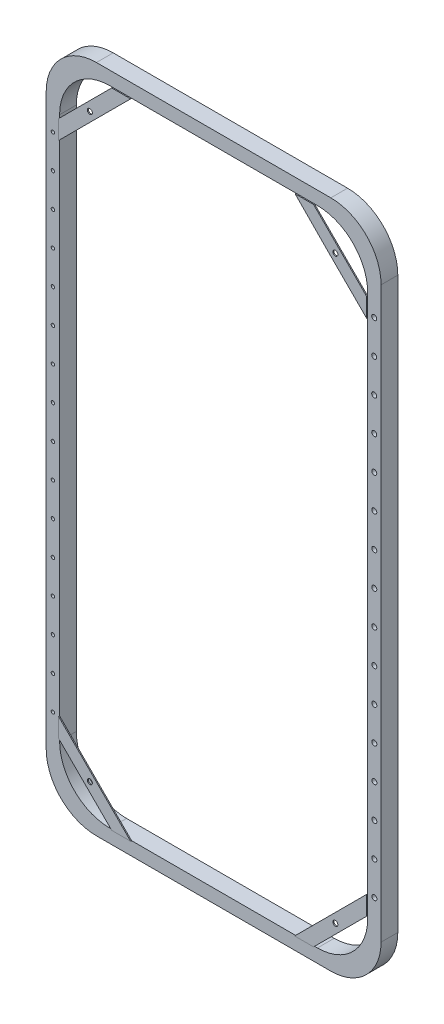
from build123d import *

# Parameters (mm, degrees)
ESTRUSIONE_ESTRUSIONE2_DEPTH = 50
RACCORDO2_R                  = 150
TAGLIO_ESTRUSIONE2_DEPTH     = 50
ESTRUSIONE_ESTRUSIONE5_DEPTH = 3
ESTRUSIONE_ESTRUSIONE6_DEPTH = 3
ESTRUSIONE_ESTRUSIONE7_DEPTH = 3
ESTRUSIONE_ESTRUSIONE8_DEPTH = 3
SCHIZZO11_R                  = 7.5
TAGLIO_ESTRUSIONE3_DEPTH     = 54
SCHIZZO12_R                  = 7.5
TAGLIO_ESTRUSIONE4_DEPTH     = 54
SCHIZZO13_R                  = 7.5
TAGLIO_ESTRUSIONE5_DEPTH     = 54
SCHIZZO14_R                  = 7.5
TAGLIO_ESTRUSIONE6_DEPTH     = 54
SCHIZZO15_R                  = 7.5
TAGLIO_ESTRUSIONE7_DEPTH     = 51
SCHIZZO16_R                  = 5
TAGLIO_ESTRUSIONE9_DEPTH     = 51


with BuildPart() as part:
    # Schizzo1 → Estrusione-Estrusione2 (new body)
    with BuildSketch(Plane.XY):
        Polygon((-204.549340991, 1000), (-500, 1000), (-500, -1000), (500, -1000), (500, 1000), align=None)
    extrude(amount=ESTRUSIONE_ESTRUSIONE2_DEPTH)

    # Raccordo2
    raccordo2_edges = [part.edges().sort_by_distance(p)[0] for p in [
        (500, -1000, 25),
        (-500, -1000, 25),
        (-500, 1000, 25),
        (500, 1000, 25),
    ]]
    fillet(raccordo2_edges, radius=RACCORDO2_R)

    # Schizzo4 → Taglio-Estrusione2 (cut)
    with BuildSketch(Plane.XY.offset(50)):
        with BuildLine():
            Line((-310, 960), (310, 960))
            ThreePointArc((310, 960), (416.066017178, 916.066017178), (460, 810))
            Line((460, 810), (460, -810))
            ThreePointArc((460, -810), (416.066017178, -916.066017178), (310, -960))
            Line((310, -960), (-310, -960))
            ThreePointArc((-310, -960), (-416.066017178, -916.066017178), (-460, -810))
            Line((-460, -810), (-460, 810))
            ThreePointArc((-460, 810), (-416.066017178, 916.066017178), (-310, 960))
        make_face()
    extrude(amount=-TAGLIO_ESTRUSIONE2_DEPTH, mode=Mode.SUBTRACT)

    # Schizzo15 → Taglio-Estrusione7 (cut, through all)
    with BuildSketch(Plane.XY.offset(50)):
        with Locations((480, -744.852813742)):
            Circle(SCHIZZO15_R)
        with Locations((479.972038493, -644.852817652)):
            Circle(SCHIZZO15_R)
        with Locations((479.944076987, -544.852821561)):
            Circle(SCHIZZO15_R)
        with Locations((479.91611548, -444.85282547)):
            Circle(SCHIZZO15_R)
        with Locations((479.888153974, -344.852829379)):
            Circle(SCHIZZO15_R)
        with Locations((479.860192467, -244.852833289)):
            Circle(SCHIZZO15_R)
        with Locations((479.83223096, -144.852837198)):
            Circle(SCHIZZO15_R)
        with Locations((479.804269454, -44.852841107)):
            Circle(SCHIZZO15_R)
        with Locations((479.776307947, 55.147154984)):
            Circle(SCHIZZO15_R)
        with Locations((479.748346441, 155.147151075)):
            Circle(SCHIZZO15_R)
        with Locations((479.720384934, 255.147147165)):
            Circle(SCHIZZO15_R)
        with Locations((479.692423427, 355.147143256)):
            Circle(SCHIZZO15_R)
        with Locations((479.664461921, 455.147139347)):
            Circle(SCHIZZO15_R)
        with Locations((479.636500414, 555.147135438)):
            Circle(SCHIZZO15_R)
        with Locations((479.608538908, 655.147131528)):
            Circle(SCHIZZO15_R)
        with Locations((479.580577401, 755.147127619)):
            Circle(SCHIZZO15_R)
    extrude(amount=-TAGLIO_ESTRUSIONE7_DEPTH, mode=Mode.SUBTRACT)

    # Schizzo16 → Taglio-Estrusione9 (cut, through all)
    with BuildSketch(Plane.XY.offset(50)):
        with Locations((-480, -744.852813742)):
            Circle(SCHIZZO16_R)
        with Locations((-480, -644.852813742)):
            Circle(SCHIZZO16_R)
        with Locations((-480, -544.852813742)):
            Circle(SCHIZZO16_R)
        with Locations((-480, -444.852813742)):
            Circle(SCHIZZO16_R)
        with Locations((-480, -344.852813742)):
            Circle(SCHIZZO16_R)
        with Locations((-480, -244.852813742)):
            Circle(SCHIZZO16_R)
        with Locations((-480, -144.852813742)):
            Circle(SCHIZZO16_R)
        with Locations((-480, -44.852813742)):
            Circle(SCHIZZO16_R)
        with Locations((-480, 55.147186258)):
            Circle(SCHIZZO16_R)
        with Locations((-480, 155.147186258)):
            Circle(SCHIZZO16_R)
        with Locations((-480, 255.147186258)):
            Circle(SCHIZZO16_R)
        with Locations((-480, 355.147186258)):
            Circle(SCHIZZO16_R)
        with Locations((-480, 455.147186258)):
            Circle(SCHIZZO16_R)
        with Locations((-480, 555.147186258)):
            Circle(SCHIZZO16_R)
        with Locations((-480, 655.147186258)):
            Circle(SCHIZZO16_R)
        with Locations((-480, 755.147186258)):
            Circle(SCHIZZO16_R)
    extrude(amount=-TAGLIO_ESTRUSIONE9_DEPTH, mode=Mode.SUBTRACT)


with BuildPart() as body_2:
    # Schizzo7 → Estrusione-Estrusione5 (new body)
    with BuildSketch(Plane.XY.offset(50)):
        Polygon((380.710678119, 880.710678119), (460, 801.421356237), (460, 744.852813742), (352.426406871, 852.426406871), (246.501635368, 960), (301.421356237, 960), align=None)
    extrude(amount=ESTRUSIONE_ESTRUSIONE5_DEPTH)

    # Schizzo12 → Taglio-Estrusione4 (cut, through all)
    with BuildSketch(Plane.XY.offset(53)):
        with Locations((366.564427275, 866.573571801)):
            Circle(SCHIZZO12_R)
    extrude(amount=-TAGLIO_ESTRUSIONE4_DEPTH, mode=Mode.SUBTRACT)


with BuildPart() as body_3:
    # Schizzo8 → Estrusione-Estrusione6 (new body)
    with BuildSketch(Plane.XY.offset(50)):
        Polygon((-301.421356237, 960), (-380.710678119, 880.710678119), (-352.426406871, 852.426406871), (-244.852813742, 960), align=None)
        Polygon((-352.426406871, 852.426406871), (-380.710678119, 880.710678119), (-460, 801.421356237), (-460, 744.852813742), align=None)
    extrude(amount=ESTRUSIONE_ESTRUSIONE6_DEPTH)

    # Schizzo11 → Taglio-Estrusione3 (cut, through all)
    with BuildSketch(Plane.XY.offset(53)):
        with Locations((-366.568542495, 866.568542495)):
            Circle(SCHIZZO11_R)
    extrude(amount=-TAGLIO_ESTRUSIONE3_DEPTH, mode=Mode.SUBTRACT)


with BuildPart() as body_4:
    # Schizzo9 → Estrusione-Estrusione7 (new body)
    with BuildSketch(Plane.XY.offset(50)):
        Polygon((-460, -801.421356237), (-380.710678119, -880.710678119), (-301.421356237, -960), (-244.852813742, -960), (-273.13708499, -931.715728753), (-460, -744.852813742), align=None)
    extrude(amount=ESTRUSIONE_ESTRUSIONE7_DEPTH)

    # Schizzo13 → Taglio-Estrusione5 (cut, through all)
    with BuildSketch(Plane.XY.offset(53)):
        with Locations((-366.568542495, -866.568542495)):
            Circle(SCHIZZO13_R)
    extrude(amount=-TAGLIO_ESTRUSIONE5_DEPTH, mode=Mode.SUBTRACT)


with BuildPart() as body_5:
    # Schizzo10 → Estrusione-Estrusione8 (new body)
    with BuildSketch(Plane.XY.offset(50)):
        Polygon((301.421356237, -960), (380.710678119, -880.710678119), (460, -801.421356237), (460, -744.852813742), (352.426406871, -852.426406871), (244.852813742, -960), align=None)
    extrude(amount=ESTRUSIONE_ESTRUSIONE8_DEPTH)

    # Schizzo14 → Taglio-Estrusione6 (cut, through all)
    with BuildSketch(Plane.XY.offset(53)):
        with Locations((366.568542495, -866.568542495)):
            Circle(SCHIZZO14_R)
    extrude(amount=-TAGLIO_ESTRUSIONE6_DEPTH, mode=Mode.SUBTRACT)


solid = Compound([part.part, body_2.part, body_3.part, body_4.part, body_5.part])
